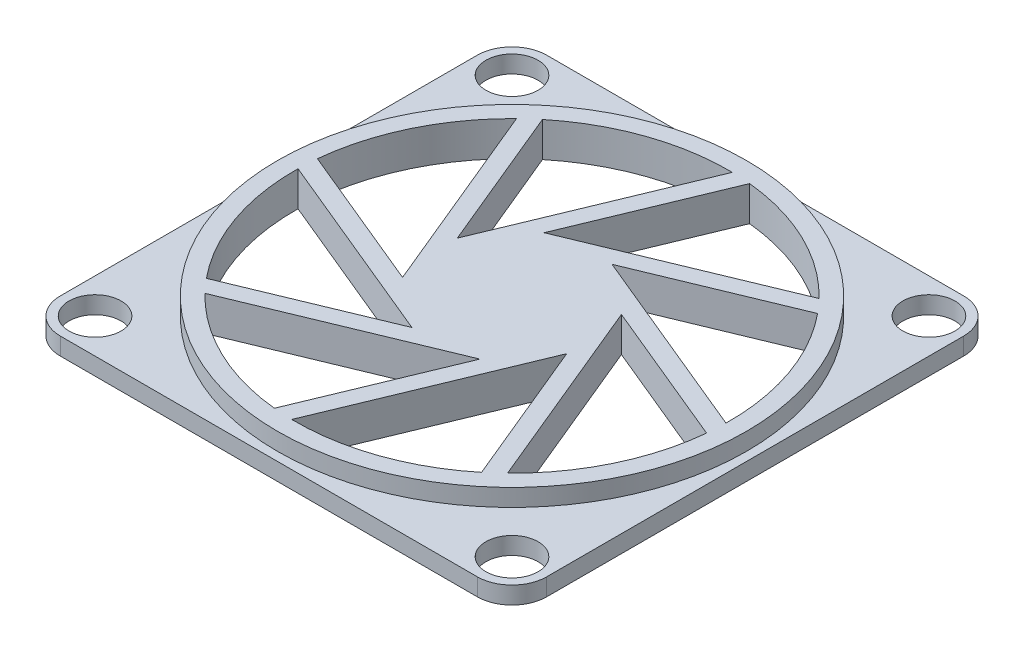
from build123d import *

# Parameters (mm, degrees)
SKETCH1_R           = 12.5
SKETCH1_R_2         = 1.5
BOSS_EXTRUDE1_DEPTH = 1
SKETCH3_R           = 13.5
SKETCH3_R_2         = 12.5
BOSS_EXTRUDE2_DEPTH = 1
BOSS_EXTRUDE3_DEPTH = 2


with BuildPart() as part:
    # Sketch1 → Boss-Extrude1 (new body)
    with BuildSketch(Plane(origin=(0, 0, 0), x_dir=(1, 0, 0), z_dir=(0, 1, 0))):
        with BuildLine():
            Line((-12, -14), (12, -14))
            ThreePointArc((12, -14), (13.414213562, -13.414213562), (14, -12))
            Line((14, -12), (14, 12))
            ThreePointArc((14, 12), (13.414213562, 13.414213562), (12, 14))
            Line((12, 14), (-12, 14))
            ThreePointArc((-12, 14), (-13.414213562, 13.414213562), (-14, 12))
            Line((-14, 12), (-14, -12))
            ThreePointArc((-14, -12), (-13.414213562, -13.414213562), (-12, -14))
        make_face()
        Circle(SKETCH1_R, mode=Mode.SUBTRACT)
        with Locations((-12, 12)):
            Circle(SKETCH1_R_2, mode=Mode.SUBTRACT)
        with Locations((12, 12)):
            Circle(SKETCH1_R_2, mode=Mode.SUBTRACT)
        with Locations((12, -12)):
            Circle(SKETCH1_R_2, mode=Mode.SUBTRACT)
        with Locations((-12, -12)):
            Circle(SKETCH1_R_2, mode=Mode.SUBTRACT)
    extrude(amount=BOSS_EXTRUDE1_DEPTH)

    # Sketch3 → Boss-Extrude2 (add)
    with BuildSketch(Plane(origin=(0, 1, 0), x_dir=(1, 0, 0), z_dir=(0, 1, 0))):
        Circle(SKETCH3_R)
        Circle(SKETCH3_R_2, mode=Mode.SUBTRACT)
    extrude(amount=BOSS_EXTRUDE2_DEPTH)

    # Sketch4 → Boss-Extrude3 (add)
    with BuildSketch(Plane(origin=(0, 0, 0), x_dir=(1, 0, 0), z_dir=(0, 1, 0))):
        with BuildLine():
            Line((-4.454043904, 1.306562965), (0.181881395, 12.498676696))
            ThreePointArc((0.181881395, 12.498676696), (0.711234958, 12.47974939), (1.239311378, 12.438412572))
            Line((1.239311378, 12.438412572), (-2.225605116, 4.073364181))
            Line((-2.225605116, 4.073364181), (8.966508616, 8.70928948))
            ThreePointArc((8.966508616, 8.70928948), (9.327434483, 8.321596359), (9.671611356, 7.918960398))
            Line((9.671611356, 7.918960398), (1.306562965, 4.454043904))
            Line((1.306562965, 4.454043904), (12.498676696, -0.181881395))
            ThreePointArc((12.498676696, -0.181881395), (12.47974939, -0.711234958), (12.438412572, -1.239311378))
            Line((12.438412572, -1.239311378), (4.073364181, 2.225605116))
            Line((4.073364181, 2.225605116), (8.70928948, -8.966508616))
            ThreePointArc((8.70928948, -8.966508616), (8.321596359, -9.327434483), (7.918960398, -9.671611356))
            Line((7.918960398, -9.671611356), (4.454043904, -1.306562965))
            Line((4.454043904, -1.306562965), (-0.181881395, -12.498676696))
            ThreePointArc((-0.181881395, -12.498676696), (-0.711234958, -12.47974939), (-1.239311378, -12.438412572))
            Line((-1.239311378, -12.438412572), (2.225605116, -4.073364181))
            Line((2.225605116, -4.073364181), (-8.966508616, -8.70928948))
            ThreePointArc((-8.966508616, -8.70928948), (-9.327434483, -8.321596359), (-9.671611356, -7.918960398))
            Line((-9.671611356, -7.918960398), (-1.306562965, -4.454043904))
            Line((-1.306562965, -4.454043904), (-12.498676696, 0.181881395))
            ThreePointArc((-12.498676696, 0.181881395), (-12.47974939, 0.711234958), (-12.438412572, 1.239311378))
            Line((-12.438412572, 1.239311378), (-4.073364181, -2.225605116))
            Line((-4.073364181, -2.225605116), (-8.70928948, 8.966508616))
            ThreePointArc((-8.70928948, 8.966508616), (-8.321596359, 9.327434483), (-7.918960398, 9.671611356))
            Line((-7.918960398, 9.671611356), (-4.454043904, 1.306562965))
        make_face()
    extrude(amount=BOSS_EXTRUDE3_DEPTH)


solid = part.part
